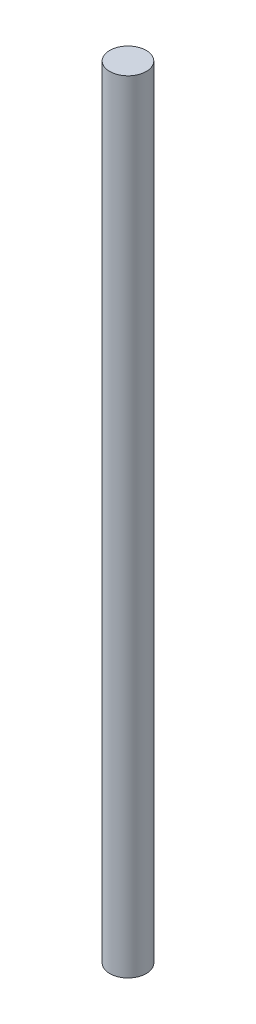
from build123d import *

# Parameters (mm, degrees)
SKETCH1_R           = 914.4
BOSS_EXTRUDE1_DEPTH = 39116


with BuildPart() as part:
    # Sketch1 → Boss-Extrude1 (new body)
    with BuildSketch(Plane(origin=(0, 0, 0), x_dir=(1, 0, 0), z_dir=(0, 1, 0))):
        Circle(SKETCH1_R)
    extrude(amount=BOSS_EXTRUDE1_DEPTH)


solid = part.part
